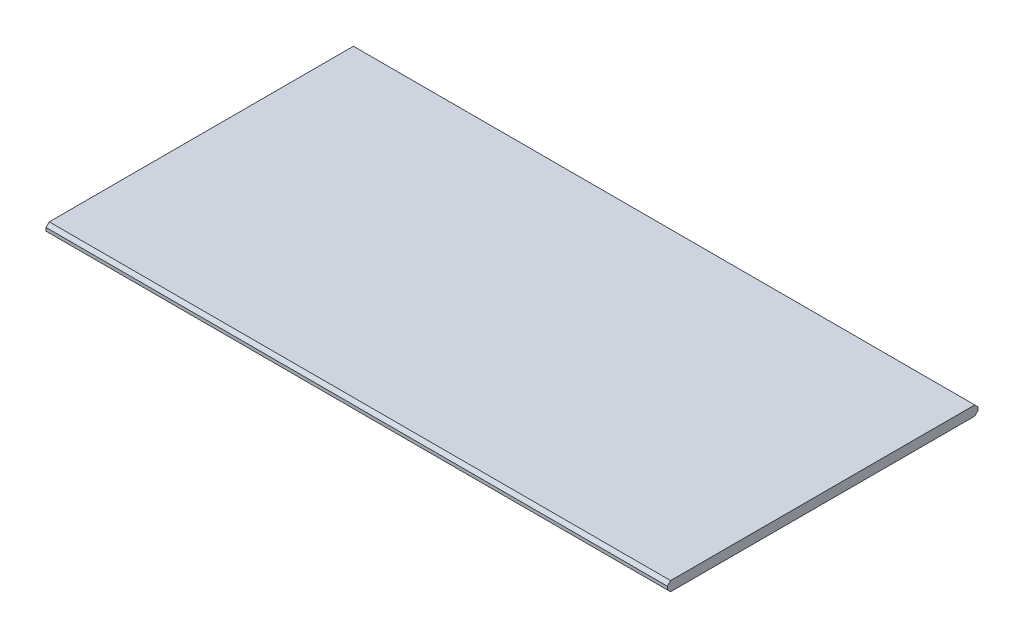
from build123d import *

# Parameters (mm, degrees)
SKETCH1_W           = 1219.2
SKETCH1_H           = 609.6
BOSS_EXTRUDE1_DEPTH = 9.525
CHAMFER1_SIZE       = 6.35


with BuildPart() as part:
    # Sketch1 → Boss-Extrude1 (new body, symmetric)
    with BuildSketch(Plane(origin=(0, 0, 0), x_dir=(1, 0, 0), z_dir=(0, 1, 0))):
        Rectangle(SKETCH1_W, SKETCH1_H)
    extrude(amount=BOSS_EXTRUDE1_DEPTH, both=True)

    # Chamfer1
    chamfer1_edges = [part.edges().sort_by_distance(p)[0] for p in [
        (0, 9.525, 304.8),
        (0, -9.525, 304.8),
        (0, -9.525, -304.8),
        (0, 9.525, -304.8),
    ]]
    chamfer(chamfer1_edges, length=CHAMFER1_SIZE)


solid = part.part
